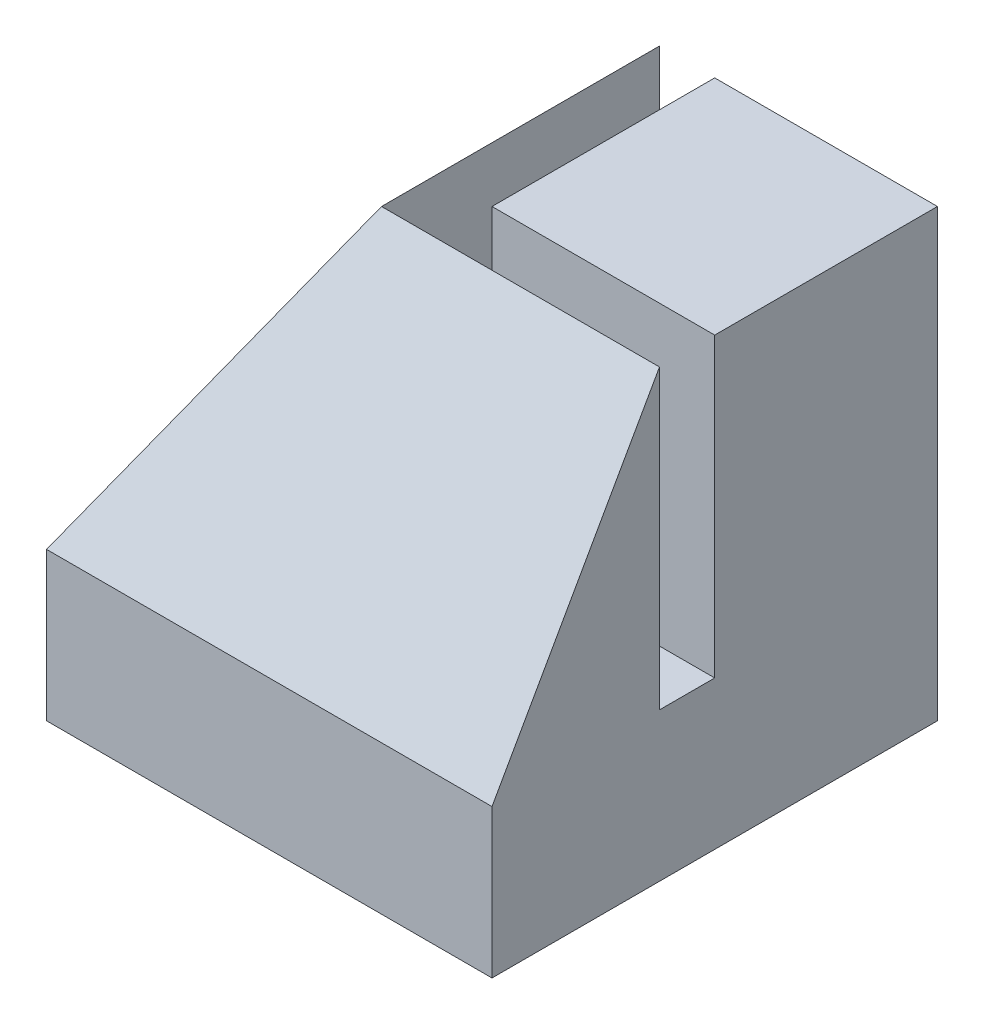
from build123d import *

# Parameters (mm, degrees)
SKETCH1_W         = 19.05
SKETCH1_H         = 19.05
BODY_DEPTH        = 19.05
SLOT_DEPTH        = 12.7
BEVEL_LEFT_DEPTH  = 19.05
BEVEL_RIGHT_DEPTH = 19.05


with BuildPart() as part:
    # Sketch1 → Body (new body)
    with BuildSketch(Plane(origin=(0, 0, 0), x_dir=(1, 0, 0), z_dir=(0, 1, 0))):
        Rectangle(SKETCH1_W, SKETCH1_H)
    extrude(amount=BODY_DEPTH)

    # Sketch2 → Slot (cut)
    with BuildSketch(Plane(origin=(0, 19.05, 0), x_dir=(1, 0, 0), z_dir=(0, 1, 0))):
        Polygon((-2.3622, 9.525), (-2.3622, -2.3622), (9.525, -2.3622), (9.525, 0), (0, 0), (0, 9.525), align=None)
    extrude(amount=-SLOT_DEPTH, mode=Mode.SUBTRACT)

    # Sketch3 → Bevel Left (cut)
    with BuildSketch(Plane.XY.offset(9.525)):
        Polygon((-2.3622, 19.05), (-9.525, 19.05), (-9.525, 6.35), align=None)
    extrude(amount=-BEVEL_LEFT_DEPTH, mode=Mode.SUBTRACT)

    # Sketch4 → Bevel Right (cut)
    with BuildSketch(Plane(origin=(9.525, 0, 0), x_dir=(0, 0, -1), z_dir=(1, 0, 0))):
        Polygon((-2.3622, 19.05), (-9.525, 6.35), (-9.525, 19.05), align=None)
    extrude(amount=-BEVEL_RIGHT_DEPTH, mode=Mode.SUBTRACT)


solid = part.part
